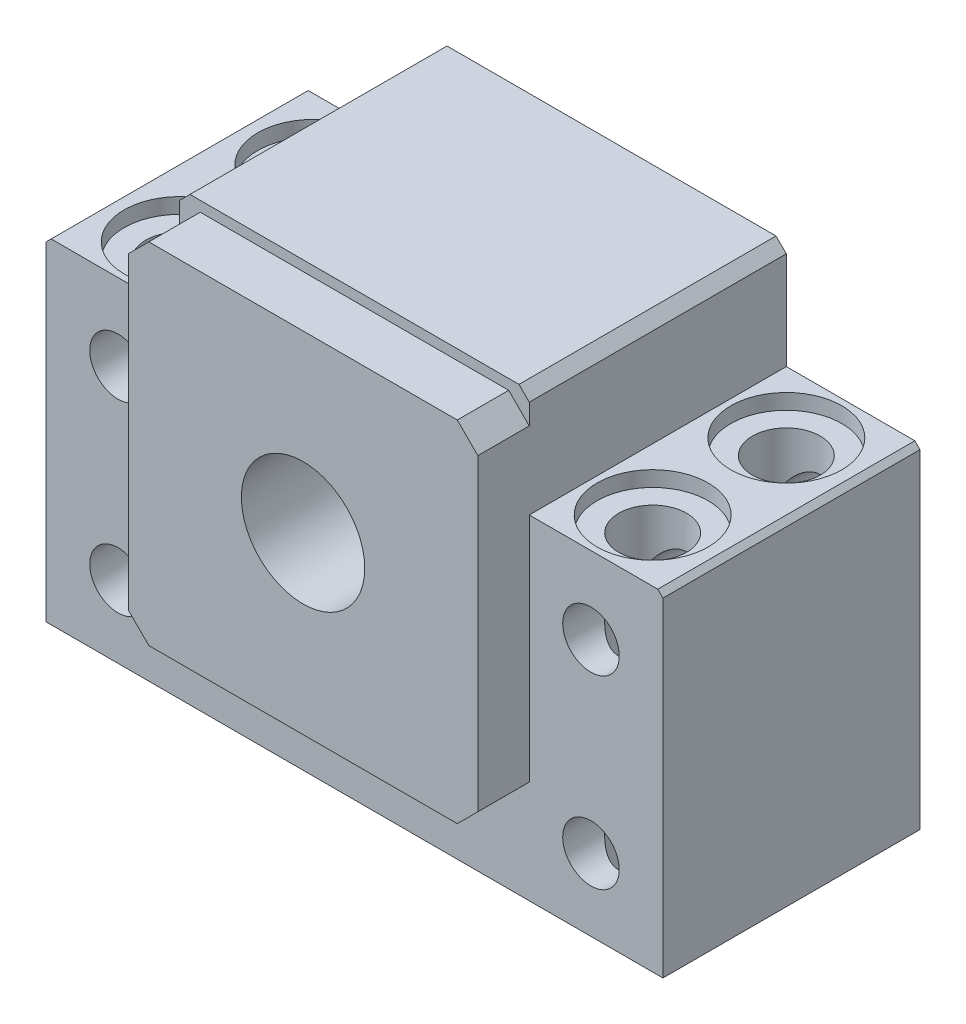
from build123d import *

# Parameters (mm, degrees)
SKETCH_1_R          = 6
SKETCH_1_R_2        = 2.75
EXTRUDE_1_DEPTH     = 25
SKETCH_2_R          = 6
EXTRUDE_2_DEPTH     = 5
CUT_EXTRUDE_START   = 7.5
SKETCH_3_R          = 3.3
CUT_EXTRUDE_1_DEPTH = 33.5
SKETCH_4_R          = 5.4
CUT_EXTRUDE_2_DEPTH = 1.5


with BuildPart() as part:
    # Эскиз1 → Бобышка-Вытянуть1 (new body)
    with BuildSketch(Plane.XY):
        Polygon((-30, 7), (-30, -25), (30, -25), (30, 7), (29.5, 7.5), (17, 7.5), (17, 17), (16, 18), (-16, 18), (-17, 17), (-17, 7.5), (-29.5, 7.5), align=None)
        Circle(SKETCH_1_R, mode=Mode.SUBTRACT)
        with Locations((-23, 0)):
            Circle(SKETCH_1_R_2, mode=Mode.SUBTRACT)
        with Locations((-23, -18)):
            Circle(SKETCH_1_R_2, mode=Mode.SUBTRACT)
        with Locations((23, -18)):
            Circle(SKETCH_1_R_2, mode=Mode.SUBTRACT)
        with Locations((23, 0)):
            Circle(SKETCH_1_R_2, mode=Mode.SUBTRACT)
    extrude(amount=-EXTRUDE_1_DEPTH)

    # Эскиз2 → Бобышка-Вытянуть2 (add)
    with BuildSketch(Plane.XY):
        Polygon((-17, 15), (-15, 17), (15, 17), (17, 15), (17, -15), (15, -17), (-15, -17), (-17, -15), align=None)
        Circle(SKETCH_2_R, mode=Mode.SUBTRACT)
    extrude(amount=EXTRUDE_2_DEPTH)

    # Эскиз3 → Вырез-Вытянуть1 (cut, through all)
    with BuildSketch(Plane(origin=(0, 0, 0), x_dir=(1, 0, 0), z_dir=(0, 1, 0)).offset(CUT_EXTRUDE_START)):
        with Locations((-23, 19)):
            Circle(SKETCH_3_R)
        with Locations((-23, 6)):
            Circle(SKETCH_3_R)
        with Locations((23, 6)):
            Circle(SKETCH_3_R)
        with Locations((23, 19)):
            Circle(SKETCH_3_R)
    extrude(amount=-CUT_EXTRUDE_1_DEPTH, mode=Mode.SUBTRACT)

    # Эскиз4 → Вырез-Вытянуть2 (cut)
    with BuildSketch(Plane(origin=(0, 0, 0), x_dir=(1, 0, 0), z_dir=(0, 1, 0)).offset(CUT_EXTRUDE_START)):
        with Locations((-23, 19)):
            Circle(SKETCH_4_R)
        with Locations((-23, 6)):
            Circle(SKETCH_4_R)
        with Locations((23, 6)):
            Circle(SKETCH_4_R)
        with Locations((23, 19)):
            Circle(SKETCH_4_R)
    extrude(amount=-CUT_EXTRUDE_2_DEPTH, mode=Mode.SUBTRACT)


solid = part.part
